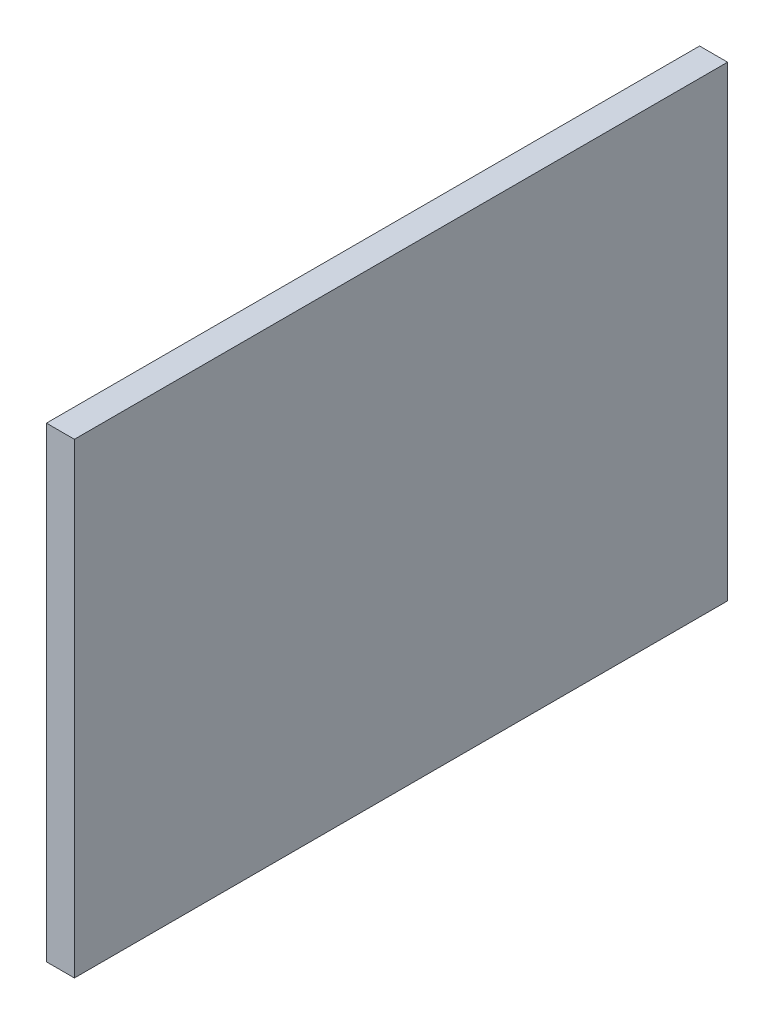
from build123d import *

# Parameters (mm, degrees)
SKETCH1_W           = 70
SKETCH1_H           = 50
BOSS_EXTRUDE1_DEPTH = 3


with BuildPart() as part:
    # Sketch1 → Boss-Extrude1 (new body)
    with BuildSketch(Plane(origin=(0, 0, 0), x_dir=(0, 0, -1), z_dir=(1, 0, 0))):
        with Locations((-16.178686095, 7.988445564)):
            Rectangle(SKETCH1_W, SKETCH1_H)
    extrude(amount=BOSS_EXTRUDE1_DEPTH)


solid = part.part
